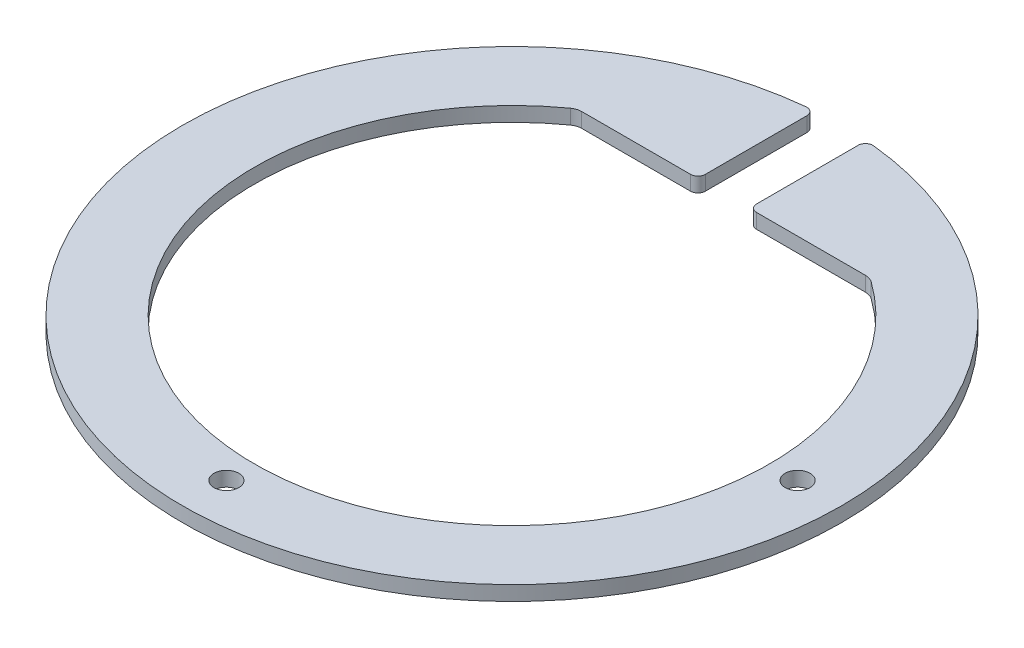
from build123d import *

# Parameters (mm, degrees)
BOSS_EXTRU_1_DEPTH      = 2
ESQUISSE2_R             = 1.7
ENL_V_MAT_EXTRU_1_DEPTH = 3
CONG_1_R                = 1
CONG_2_R                = 2


with BuildPart() as part:
    # Esquisse1 → Boss.-Extru.1 (new body)
    with BuildSketch(Plane(origin=(0, 0, 0), x_dir=(1, 0, 0), z_dir=(0, 1, 0))):
        with BuildLine():
            Line((-3.5, 28.89), (-3.5, 44.863682417))
            ThreePointArc((-3.5, 44.863682417), (0, -45), (3.5, 44.863682417))
            Line((3.5, 44.863682417), (3.5, 28.89))
            Line((3.5, 28.89), (20, 28.89))
            ThreePointArc((20, 28.89), (0, -35.137331999), (-20, 28.89))
            Line((-20, 28.89), (-3.5, 28.89))
        make_face()
    extrude(amount=BOSS_EXTRU_1_DEPTH)

    # Esquisse2 → Enlèv. mat.-Extru.1 (cut, through all)
    with BuildSketch(Plane(origin=(0, 2, 0), x_dir=(1, 0, 0), z_dir=(0, 1, 0))):
        with Locations((39, 0)):
            Circle(ESQUISSE2_R)
        with Locations((0, -39)):
            Circle(ESQUISSE2_R)
    extrude(amount=-ENL_V_MAT_EXTRU_1_DEPTH, mode=Mode.SUBTRACT)

    # Congé1
    cong_1_edges = [part.edges().sort_by_distance(p)[0] for p in [
        (-3.5, 1, -44.863682417),
        (-3.5, 1, -28.89),
        (3.5, 1, -28.89),
        (3.5, 1, -44.863682417),
    ]]
    fillet(cong_1_edges, radius=CONG_1_R)

    # Congé2
    cong_2_edges = [part.edges().sort_by_distance(p)[0] for p in [
        (-20, 1, -28.89),
        (20, 1, -28.89),
    ]]
    fillet(cong_2_edges, radius=CONG_2_R)


solid = part.part
